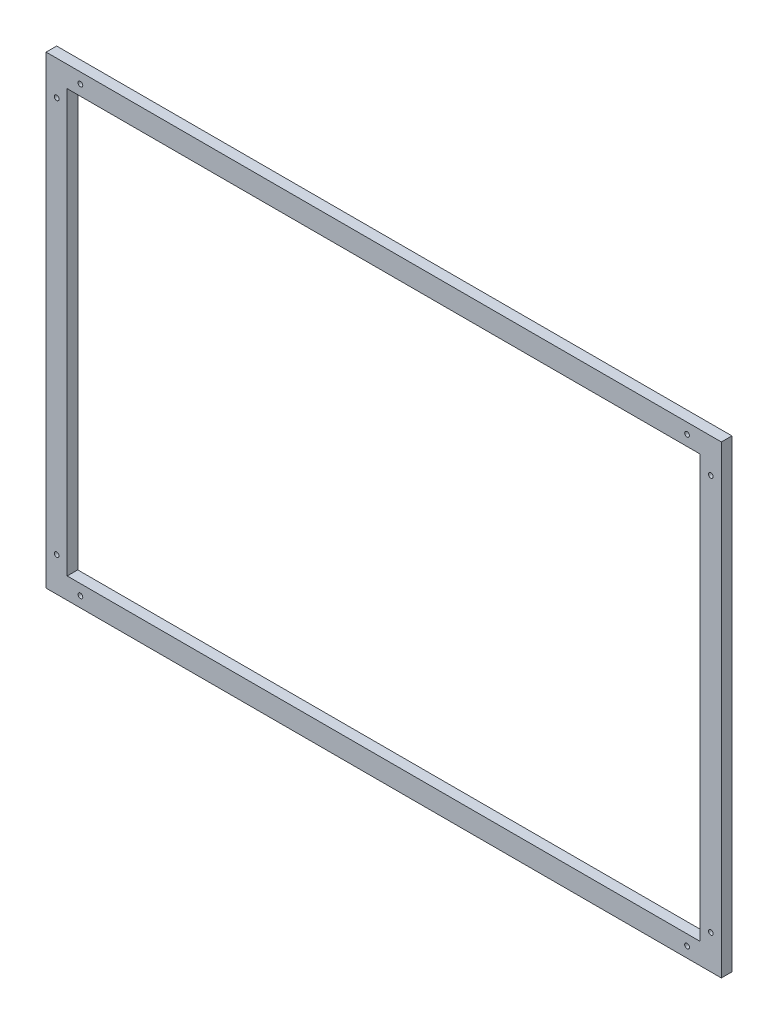
from build123d import *

# Parameters (mm, degrees)
ESQUISSE1_W             = 640
ESQUISSE1_H             = 440
ESQUISSE1_W_2           = 600
ESQUISSE1_H_2           = 400
BOSS_EXTRU_1_DEPTH      = 10
ESQUISSE2_R             = 2.25
ENL_V_MAT_EXTRU_1_DEPTH = 11


with BuildPart() as part:
    # Esquisse1 → Boss.-Extru.1 (new body)
    with BuildSketch(Plane.XY):
        with Locations((-320, 220)):
            Rectangle(ESQUISSE1_W, ESQUISSE1_H)
        with Locations((-320, 220)):
            Rectangle(ESQUISSE1_W_2, ESQUISSE1_H_2, mode=Mode.SUBTRACT)
    extrude(amount=BOSS_EXTRU_1_DEPTH)

    # Esquisse2 → Enlèv. mat.-Extru.1 (cut, through all)
    with BuildSketch(Plane.XY.offset(10)):
        with Locations((-32.5, 430)):
            Circle(ESQUISSE2_R)
        with Locations((-10, 407.5)):
            Circle(ESQUISSE2_R)
        with Locations((-607.5, 430)):
            Circle(ESQUISSE2_R)
        with Locations((-630, 407.5)):
            Circle(ESQUISSE2_R)
        with Locations((-630, 32.5)):
            Circle(ESQUISSE2_R)
        with Locations((-607.5, 10)):
            Circle(ESQUISSE2_R)
        with Locations((-32.5, 10)):
            Circle(ESQUISSE2_R)
        with Locations((-10, 32.5)):
            Circle(ESQUISSE2_R)
    extrude(amount=-ENL_V_MAT_EXTRU_1_DEPTH, mode=Mode.SUBTRACT)


solid = part.part
